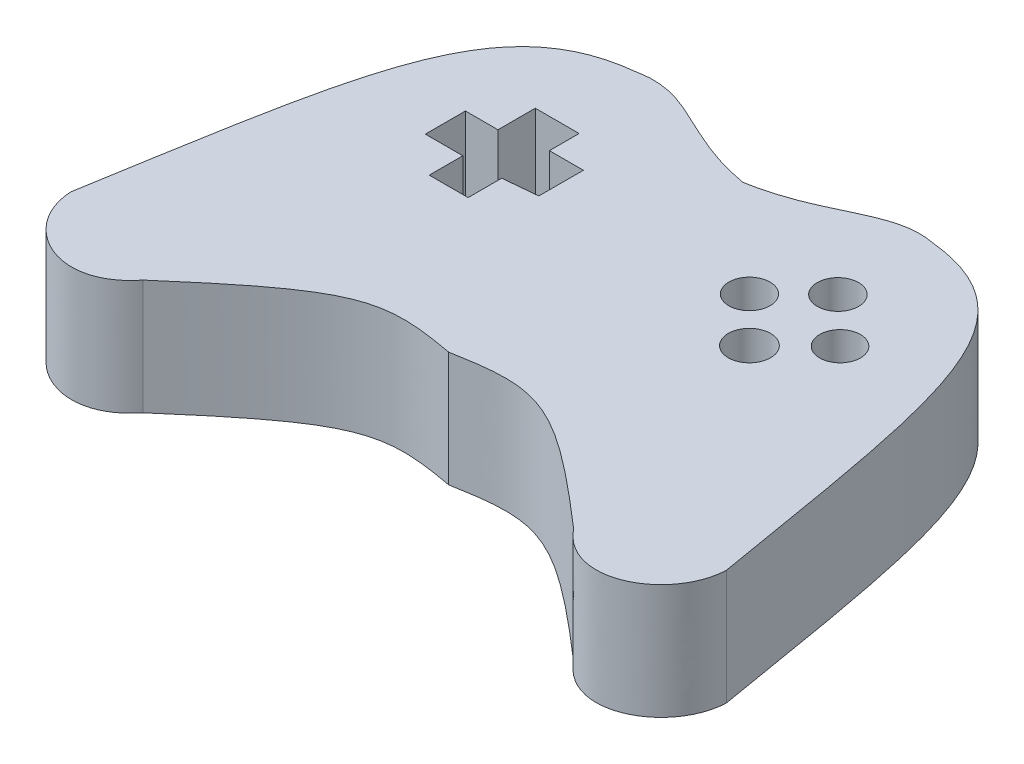
from build123d import *

# Parameters (mm, degrees)
SKETCH1_R           = 0.358119717
SKETCH1_R_2         = 0.367977628
SKETCH1_R_3         = 0.354400667
SKETCH1_R_4         = 0.360009999
BOSS_EXTRUDE1_DEPTH = 2


with BuildPart() as part:
    # Sketch1 → Boss-Extrude1 (new body)
    with BuildSketch(Plane(origin=(0, 0, 0), x_dir=(1, 0, 0), z_dir=(0, 1, 0))):
        with BuildLine():
            add(Edge.make_bspline(
                [(9.515794057, 8.168972603), (8.277051231, 8.384166889), (7.783662178, 9.075903216), (6.938322746, 8.906835329)],
                knots=[0, 0, 0, 0, 1, 1, 1, 1], degree=3))
            add(Edge.make_bspline(
                [(6.938322746, 8.906835329), (4.786223752, 8.676253294), (4.567934499, 6.637882364), (3.814703871, 2.179986806)],
                knots=[0, 0, 0, 0, 1, 1, 1, 1], degree=3))
            add(Edge.make_bspline(
                [(3.814703871, 2.179986806), (3.85569383, 1.237217744), (5.062947097, 0.587465173), (5.770040096, 1.479017216)],
                knots=[0, 0, 0, 0, 1, 1, 1, 1], degree=3))
            add(Edge.make_bspline(
                [(5.770040096, 1.479017216), (7.783771597, 3.231424782), (8.154064913, 3.299063972), (9.515794057, 3.053124366)],
                knots=[0, 0, 0, 0, 1, 1, 1, 1], degree=3))
            add(Edge.make_bspline(
                [(13.261548017, 1.479017216), (11.247816516, 3.231424782), (10.8775232, 3.299063972), (9.515794057, 3.053124366)],
                knots=[0, 0, 0, 0, 1, 1, 1, 1], degree=3))
            add(Edge.make_bspline(
                [(15.216884243, 2.179986806), (15.175894283, 1.237217744), (13.968641017, 0.587465173), (13.261548017, 1.479017216)],
                knots=[0, 0, 0, 0, 1, 1, 1, 1], degree=3))
            add(Edge.make_bspline(
                [(12.093265367, 8.906835329), (14.245364361, 8.676253294), (14.463653614, 6.637882364), (15.216884243, 2.179986806)],
                knots=[0, 0, 0, 0, 1, 1, 1, 1], degree=3))
            add(Edge.make_bspline(
                [(9.515794057, 8.168972603), (10.754536882, 8.384166889), (11.247925935, 9.075903216), (12.093265367, 8.906835329)],
                knots=[0, 0, 0, 0, 1, 1, 1, 1], degree=3))
        make_face()
        with Locations((11.254257148, 6.545084301)):
            Circle(SKETCH1_R, mode=Mode.SUBTRACT)
        with Locations((12.032572113, 5.766769337)):
            Circle(SKETCH1_R_2, mode=Mode.SUBTRACT)
        with Locations((12.830512487, 6.545084301)):
            Circle(SKETCH1_R_3, mode=Mode.SUBTRACT)
        with Locations((12.032572113, 7.306018511)):
            Circle(SKETCH1_R_4, mode=Mode.SUBTRACT)
        Polygon((6.680070792, 7.480300725), (7.356444958, 7.480300725), (7.356444958, 6.963796816), (7.946735139, 6.963796816), (7.946735139, 6.189040953), (7.356444958, 6.133334516), (7.356444958, 5.549559924), (6.680070792, 5.549559924), (6.680070792, 6.133334516), (6.02829205, 6.133334516), (6.02829205, 6.831056674), (6.593986807, 6.831056674), (6.593986807, 7.480300725), align=None, mode=Mode.SUBTRACT)
    extrude(amount=BOSS_EXTRUDE1_DEPTH)


solid = part.part
